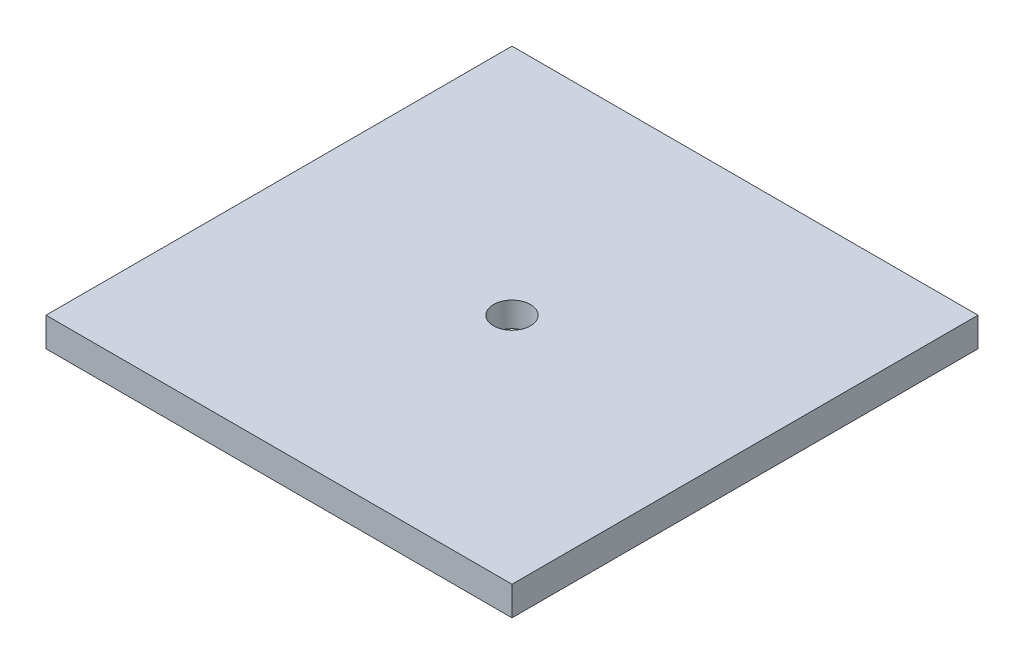
from build123d import *

# Parameters (mm, degrees)
SKETCH1_W           = 203.2
SKETCH1_H           = 203.2
BOSS_EXTRUDE1_DEPTH = 12.7
SKETCH2_R           = 8.0645
CUT_EXTRUDE1_DEPTH  = 10.795


with BuildPart() as part:
    # Sketch1 → Boss-Extrude1 (new body)
    with BuildSketch(Plane(origin=(0, 0, 0), x_dir=(1, 0, 0), z_dir=(0, 1, 0))):
        Rectangle(SKETCH1_W, SKETCH1_H)
    extrude(amount=BOSS_EXTRUDE1_DEPTH)

    # Sketch2 → Cut-Extrude1 (cut)
    with BuildSketch(Plane(origin=(0, 12.7, 0), x_dir=(1, 0, 0), z_dir=(0, 1, 0))):
        Circle(SKETCH2_R)
    extrude(amount=-CUT_EXTRUDE1_DEPTH, mode=Mode.SUBTRACT)


solid = part.part
